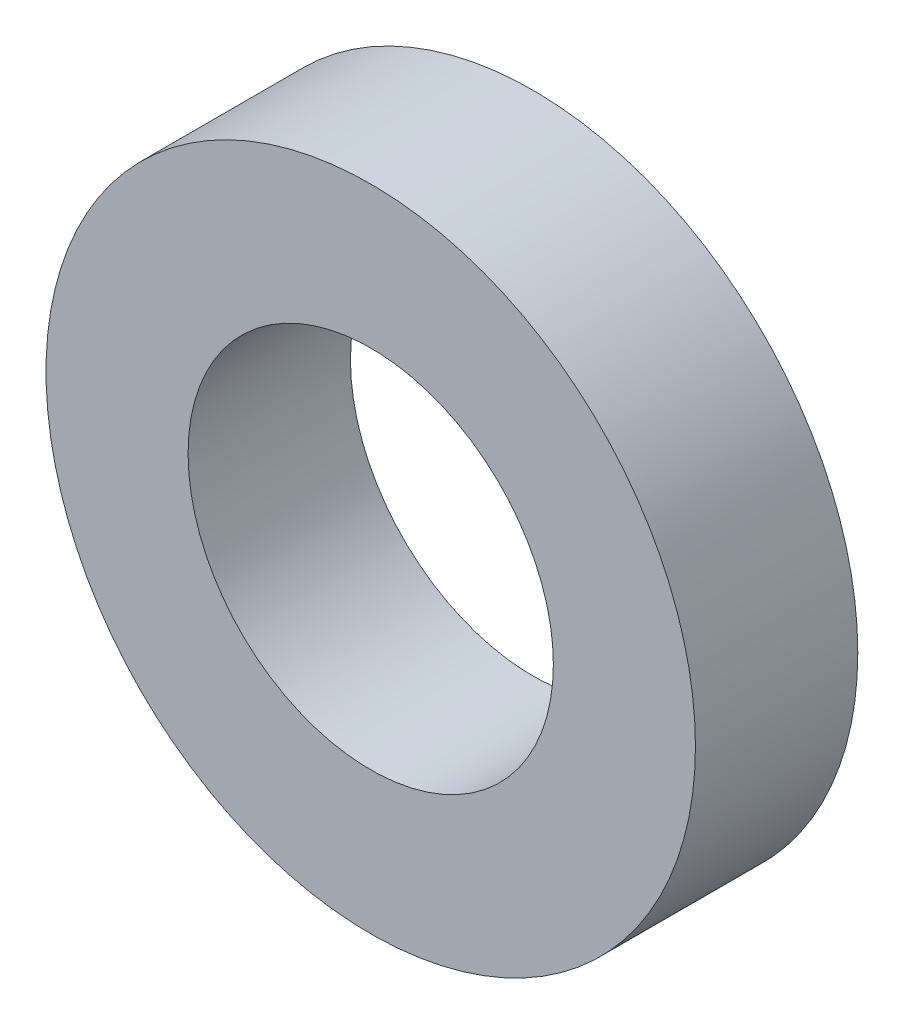
from build123d import *

# Parameters (mm, degrees)
SKETCH_1_R      = 4
SKETCH_1_R_2    = 2.25
EXTRUDE_1_DEPTH = 2


with BuildPart() as part:
    # 草图1 → 凸台-拉伸1 (new body)
    with BuildSketch(Plane.XY):
        Circle(SKETCH_1_R)
        Circle(SKETCH_1_R_2, mode=Mode.SUBTRACT)
    extrude(amount=EXTRUDE_1_DEPTH)


solid = part.part
